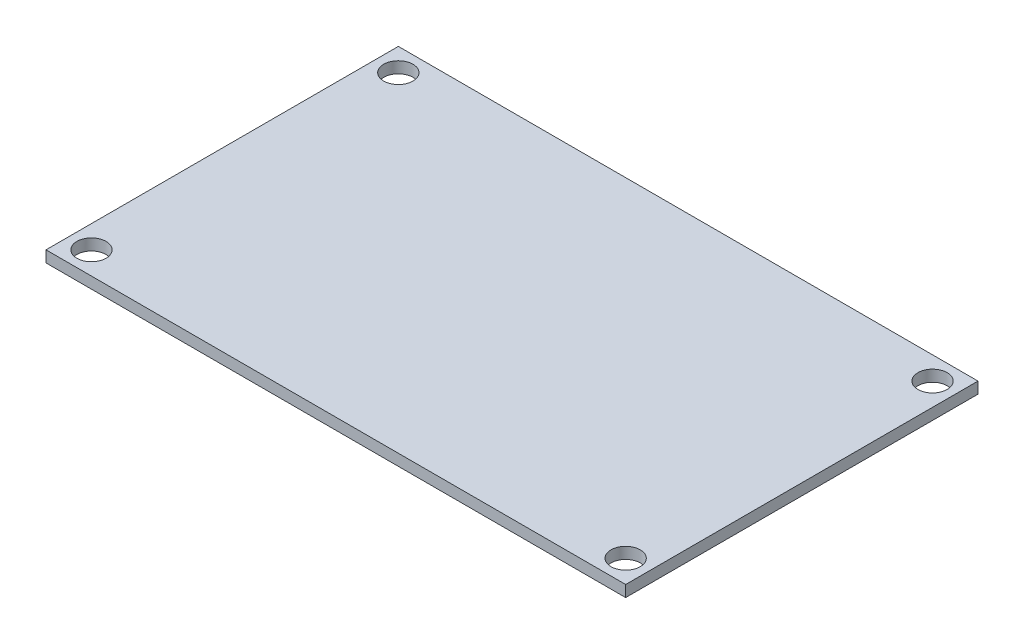
from build123d import *

# Parameters (mm, degrees)
SKETCH1_W                 = 64.77
SKETCH1_H                 = 39.37
BOSS_EXTRUDE1_DEPTH       = 1.27
F_4_CLEARANCE_HOLE1_D     = 3.2639
F_4_CLEARANCE_HOLE1_DEPTH = 7.5946
F_4_CLEARANCE_HOLE1_TIP   = 0.980574487


with BuildPart() as part:
    # Sketch1 → Boss-Extrude1 (new body)
    with BuildSketch(Plane(origin=(0, 0, 0), x_dir=(1, 0, 0), z_dir=(0, 1, 0))):
        Rectangle(SKETCH1_W, SKETCH1_H)
    extrude(amount=BOSS_EXTRUDE1_DEPTH)

    # #4 Clearance Hole1
    with Locations(Plane(origin=(0, 1.27, 0), x_dir=(1, 0, 0), z_dir=(0, 1, 0))):
        with Locations((-29.845, 17.145), (-29.845, -17.145), (29.845, -17.145), (29.845, 17.145)):
            Hole(F_4_CLEARANCE_HOLE1_D / 2, depth=F_4_CLEARANCE_HOLE1_DEPTH)
            with Locations((0, 0, -(F_4_CLEARANCE_HOLE1_DEPTH + F_4_CLEARANCE_HOLE1_TIP / 2))):  # 118° drill point
                Cone(0, F_4_CLEARANCE_HOLE1_D / 2, F_4_CLEARANCE_HOLE1_TIP, mode=Mode.SUBTRACT)


solid = part.part
